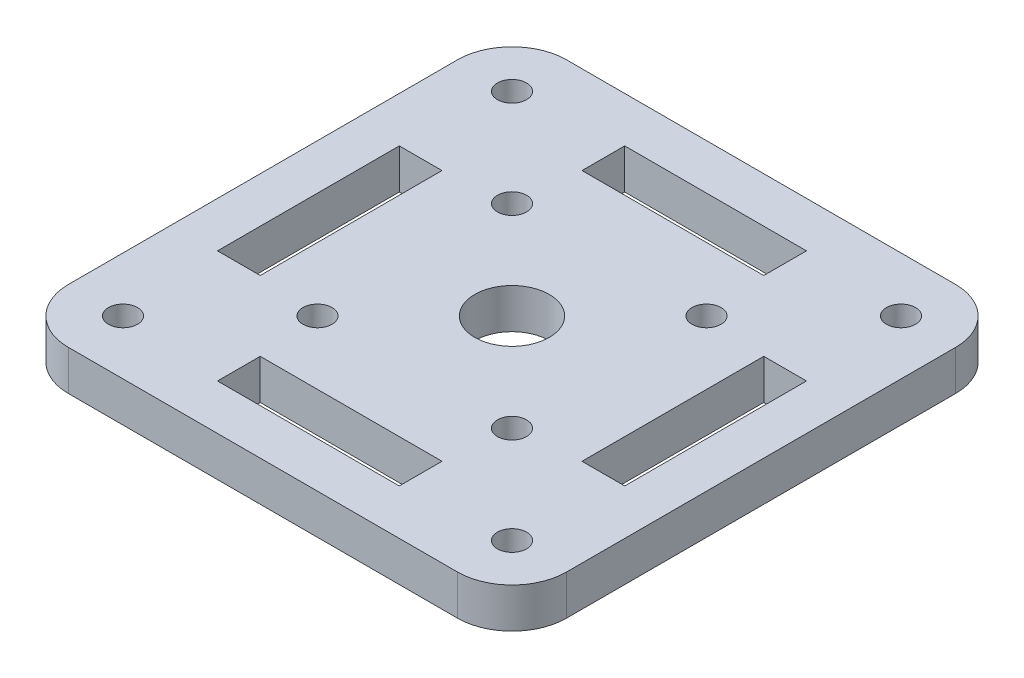
from build123d import *

# Parameters (mm, degrees)
SKETCH_1_W          = 54.8
SKETCH_1_H          = 54.8
SKETCH_1_R          = 4.1
SKETCH_1_R_2        = 1.6
EXTRUDE_1_DEPTH     = 4.4
FILLET_1_R          = 6
SKETCH_2_R          = 1.6
CUT_EXTRUDE_1_DEPTH = 10


with BuildPart() as part:
    # 草图1 → 凸台-拉伸1 (new body)
    with BuildSketch(Plane(origin=(0, 0, 0), x_dir=(1, 0, 0), z_dir=(0, 1, 0))):
        Rectangle(SKETCH_1_W, SKETCH_1_H)
        Circle(SKETCH_1_R, mode=Mode.SUBTRACT)
        with Locations((21.4, 21.4)):
            Circle(SKETCH_1_R_2, mode=Mode.SUBTRACT)
        with Locations((21.4, -21.4)):
            Circle(SKETCH_1_R_2, mode=Mode.SUBTRACT)
        with Locations((-21.4, -21.4)):
            Circle(SKETCH_1_R_2, mode=Mode.SUBTRACT)
        with Locations((-21.4, 21.4)):
            Circle(SKETCH_1_R_2, mode=Mode.SUBTRACT)
        Polygon((17.7, -5), (17.7, 5), (17.7, 10), (22.4, 10), (22.4, 5), (22.4, -5), (22.4, -10), (17.7, -10), align=None, mode=Mode.SUBTRACT)
        Polygon((-5, 17.7), (-10, 17.7), (-10, 22.4), (-5, 22.4), (5, 22.4), (10, 22.4), (10, 17.7), (5, 17.7), align=None, mode=Mode.SUBTRACT)
        Polygon((5, -17.7), (10, -17.7), (10, -22.4), (5, -22.4), (-5, -22.4), (-10, -22.4), (-10, -17.7), (-5, -17.7), align=None, mode=Mode.SUBTRACT)
        Polygon((-17.7, 5), (-17.7, -5), (-17.7, -10), (-22.4, -10), (-22.4, -5), (-22.4, 5), (-22.4, 10), (-17.7, 10), align=None, mode=Mode.SUBTRACT)
    extrude(amount=EXTRUDE_1_DEPTH)

    # 圆角1
    fillet_1_edges = [part.edges().sort_by_distance(p)[0] for p in [
        (27.4, 2.2, 27.4),
        (-27.4, 2.2, 27.4),
        (-27.4, 2.2, -27.4),
        (27.4, 2.2, -27.4),
    ]]
    fillet(fillet_1_edges, radius=FILLET_1_R)

    # 草图2 → 切除-拉伸1 (cut)
    with BuildSketch(Plane(origin=(0, 4.4, 0), x_dir=(1, 0, 0), z_dir=(0, 1, 0))):
        with Locations((10.7, 10.7)):
            Circle(SKETCH_2_R)
        with Locations((10.7, -10.7)):
            Circle(SKETCH_2_R)
        with Locations((-10.7, -10.7)):
            Circle(SKETCH_2_R)
        with Locations((-10.7, 10.7)):
            Circle(SKETCH_2_R)
    extrude(amount=-CUT_EXTRUDE_1_DEPTH, mode=Mode.SUBTRACT)


solid = part.part
